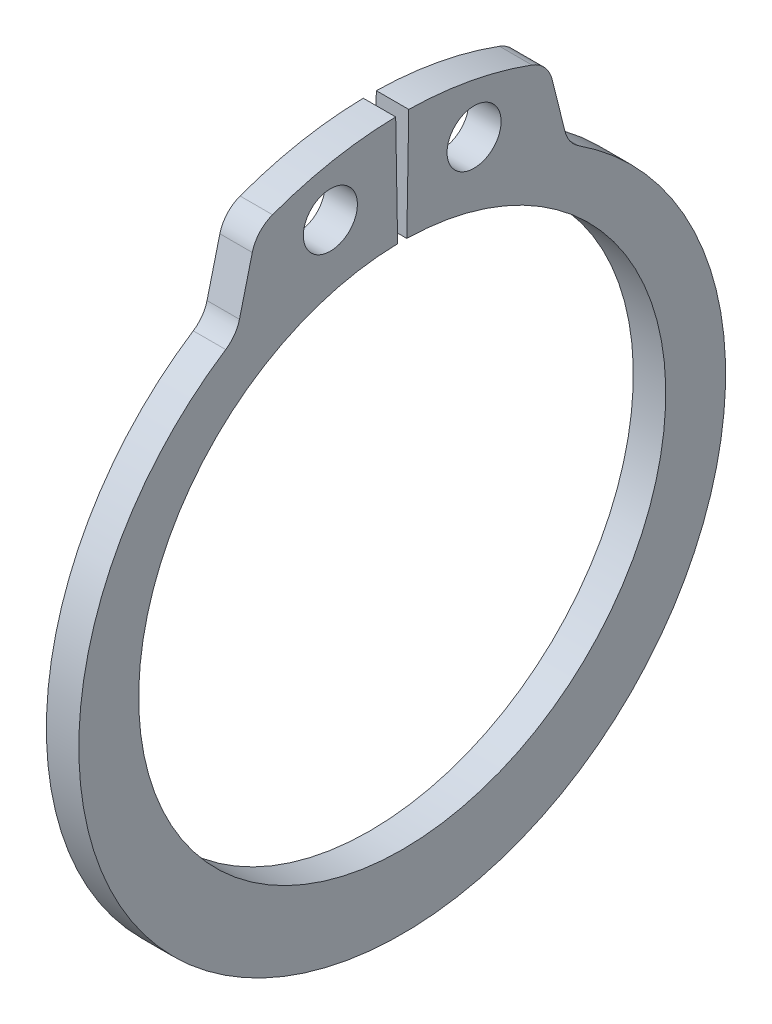
from build123d import *

# Parameters (mm, degrees)
SKETCH1_R           = 1
BOSS_EXTRUDE1_DEPTH = 1.2


with BuildPart() as part:
    # Sketch1 → Boss-Extrude1 (new body)
    with BuildSketch(Plane(origin=(-0.6, 0, 0), x_dir=(0, -1, 0), z_dir=(-1, 0, 0))):
        with BuildLine():
            Line((-10.254517122, 6.020654884), (-12.157117236, 5.546283398))
            ThreePointArc((-12.157117236, 5.546283398), (-12.667686664, 5.275571693), (-12.992516349, 4.797605541))
            ThreePointArc((-12.992516349, 4.797605541), (-13.612159776, 2.555700733), (-13.847890578, 0.241715829))
            Line((-13.847890578, 0.241715829), (-9.748515028, 0.170160963))
            ThreePointArc((-9.748515028, 0.170160963), (9.75, 0), (-9.748515028, -0.170160963))
            Line((-9.748515028, -0.170160963), (-13.847890578, -0.241715829))
            ThreePointArc((-13.847890578, -0.241715829), (-13.612159776, -2.555700733), (-12.992516349, -4.797605541))
            ThreePointArc((-12.992516349, -4.797605541), (-12.667686664, -5.275571693), (-12.157117236, -5.546283398))
            Line((-12.157117236, -5.546283398), (-10.254517122, -6.020654884))
            ThreePointArc((-10.254517122, -6.020654884), (-9.848654609, -6.207590185), (-9.539322273, -6.530053659))
            ThreePointArc((-9.539322273, -6.530053659), (12.45, 0), (-9.539322273, 6.530053659))
            ThreePointArc((-9.539322273, 6.530053659), (-9.848654609, 6.207590185), (-10.254517122, 6.020654884))
        make_face()
        with Locations((-11.755399891, -2.658115574)):
            Circle(SKETCH1_R, mode=Mode.SUBTRACT)
        with Locations((-11.755399891, 2.658115574)):
            Circle(SKETCH1_R, mode=Mode.SUBTRACT)
    extrude(amount=-BOSS_EXTRUDE1_DEPTH)


solid = part.part
